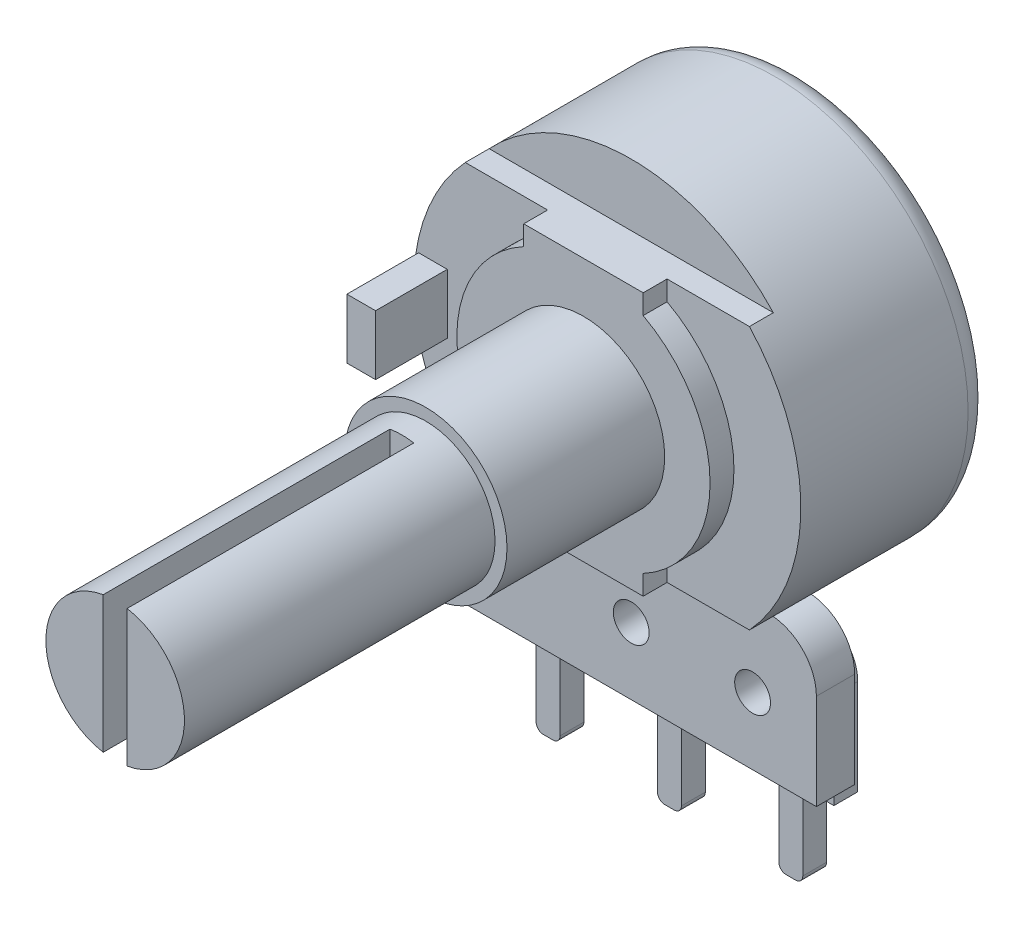
from build123d import *
from build123d.topology import SkipClean

# Parameters (mm, degrees)
IZIM1_R                     = 8.1
Y_KSEKLIK_EKSTR_ZYON1_DEPTH = 7
RADYUS1_R                   = 1
Y_KSEKLIK_EKSTR_ZYON2_DEPTH = 1
Y_KSEKLIK_EKSTR_ZYON3_DEPTH = 1
IZIM4_W                     = 1.2
IZIM4_H                     = 2.5
Y_KSEKLIK_EKSTR_ZYON4_DEPTH = 3
IZIM5_R                     = 3.4
Y_KSEKLIK_EKSTR_ZYON5_DEPTH = 6.6
IZIM6_R                     = 2.9
Y_KSEKLIK_EKSTR_ZYON6_DEPTH = 1
Y_KSEKLIK_EKSTR_ZYON7_DEPTH = 12
IZIM8_W                     = 13.702328024
IZIM8_H                     = 4.535329086
KES_EKSTR_ZYON1_DEPTH       = 3.5
Y_KSEKLIK_EKSTR_ZYON8_START = 1.9
IZIM9_R                     = 0.75
Y_KSEKLIK_EKSTR_ZYON8_DEPTH = 1.6
Y_KSEKLIK_EKSTR_ZYON9_DEPTH = 1


with BuildPart() as part:
    # Çizim1 → Yükseklik-Ekstrüzyon1 (new body)
    with BuildSketch(Plane.XY):
        Circle(IZIM1_R)
    extrude(amount=Y_KSEKLIK_EKSTR_ZYON1_DEPTH)

    # Radyus1
    radyus1_edges = [part.edges().sort_by_distance(p)[0] for p in [
        (-8.1, 0, 0),
    ]]
    fillet(radyus1_edges, radius=RADYUS1_R)

    # Çizim2 → Yükseklik-Ekstrüzyon2 (add)
    with SkipClean():  # the faces are left unmerged after this step: merging them gives an invalid solid
        with BuildSketch(Plane.XY.offset(7)):
            with BuildLine():
                Line((-5.946427499, 5.5), (5.946427499, 5.5))
                ThreePointArc((5.946427499, 5.5), (8.1, 0), (5.946427499, -5.5))
                Line((5.946427499, -5.5), (-5.946427499, -5.5))
                ThreePointArc((-5.946427499, -5.5), (-8.1, 0), (-5.946427499, 5.5))
            make_face()
        extrude(amount=Y_KSEKLIK_EKSTR_ZYON2_DEPTH)

    # Çizim3 → Yükseklik-Ekstrüzyon3 (add)
    with BuildSketch(Plane.XY.offset(8)):
        with BuildLine():
            Line((-2.5, 5.5), (2.5, 5.5))
            Line((2.5, 5.5), (2.5, 4.673328578))
            ThreePointArc((2.5, 4.673328578), (5.3, 0), (2.5, -4.673328578))
            Line((2.5, -4.673328578), (2.5, -5.5))
            Line((2.5, -5.5), (-2.5, -5.5))
            Line((-2.5, -5.5), (-2.5, -4.673328578))
            ThreePointArc((-2.5, -4.673328578), (-5.3, 0), (-2.5, 4.673328578))
            Line((-2.5, 4.673328578), (-2.5, 5.5))
        make_face()
    extrude(amount=Y_KSEKLIK_EKSTR_ZYON3_DEPTH)

    # Çizim4 → Yükseklik-Ekstrüzyon4 (add)
    with BuildSketch(Plane.XY.offset(8)):
        with Locations((-7.3, 0)):
            Rectangle(IZIM4_W, IZIM4_H)
    extrude(amount=Y_KSEKLIK_EKSTR_ZYON4_DEPTH)

    # Çizim5 → Yükseklik-Ekstrüzyon5 (add)
    with BuildSketch(Plane.XY.offset(9)):
        Circle(IZIM5_R)
    extrude(amount=Y_KSEKLIK_EKSTR_ZYON5_DEPTH)

    # Çizim6 → Yükseklik-Ekstrüzyon6 (add)
    with BuildSketch(Plane.XY.offset(15.6)):
        Circle(IZIM6_R)
    extrude(amount=Y_KSEKLIK_EKSTR_ZYON6_DEPTH)

    # Çizim7 → Yükseklik-Ekstrüzyon7 (add)
    with SkipClean():  # the faces are left unmerged after this step: merging them gives an invalid solid
        with BuildSketch(Plane.XY.offset(16.6)):
            with BuildLine():
                Line((-0.5, 2.856571371), (-0.5, -2.856571371))
                ThreePointArc((-0.5, -2.856571371), (-2.9, 0), (-0.5, 2.856571371))
            make_face()
            with BuildLine():
                Line((0.5, 2.856571371), (0.5, -2.856571371))
                ThreePointArc((0.5, -2.856571371), (2.9, 0), (0.5, 2.856571371))
            make_face()
        extrude(amount=Y_KSEKLIK_EKSTR_ZYON7_DEPTH)

    # Çizim8 → Kes-Ekstrüzyon1 (cut)
    with BuildSketch(Plane.XY.offset(7)):
        with Locations((0.904736513, -7.767664543)):
            Rectangle(IZIM8_W, IZIM8_H)
    extrude(amount=-KES_EKSTR_ZYON1_DEPTH, mode=Mode.SUBTRACT)

    # Çizim9 → Yükseklik-Ekstrüzyon8 (add)
    with BuildSketch(Plane.XY.offset(3.5).offset(Y_KSEKLIK_EKSTR_ZYON8_START)):
        with BuildLine():
            Line((-7.75, -11.5), (7.75, -11.5))
            Line((7.75, -11.5), (7.75, -7.5))
            ThreePointArc((7.75, -7.5), (7.164213562, -6.085786438), (5.75, -5.5))
            Line((5.75, -5.5), (-5.75, -5.5))
            ThreePointArc((-5.75, -5.5), (-7.164213562, -6.085786438), (-7.75, -7.5))
            Line((-7.75, -7.5), (-7.75, -11.5))
        make_face()
        with Locations((0, -8.7)):
            Circle(IZIM9_R, mode=Mode.SUBTRACT)
        with Locations((5.08, -8.7)):
            Circle(IZIM9_R, mode=Mode.SUBTRACT)
        with Locations((-5.08, -8.7)):
            Circle(IZIM9_R, mode=Mode.SUBTRACT)
    extrude(amount=Y_KSEKLIK_EKSTR_ZYON8_DEPTH)

    # Çizim10 → Yükseklik-Ekstrüzyon9 (add)
    with BuildSketch(Plane(origin=(0, 0, 5.4), x_dir=(-1, 0, 0), z_dir=(0, 0, -1))):
        with BuildLine():
            Line((3.53, -12.7), (4.58, -12))
            Line((4.58, -12), (4.58, -15.9))
            ThreePointArc((4.58, -15.9), (4.667867966, -16.112132034), (4.88, -16.2))
            Line((4.88, -16.2), (5.28, -16.2))
            ThreePointArc((5.28, -16.2), (5.492132034, -16.112132034), (5.58, -15.9))
            Line((5.58, -15.9), (5.58, -12))
            Line((5.58, -12), (6.63, -12.7))
            Line((6.63, -12.7), (6.88, -12.7))
            Line((6.88, -12.7), (6.88, -8.7))
            ThreePointArc((6.88, -8.7), (5.08, -6.9), (3.28, -8.7))
            Line((3.28, -8.7), (3.28, -12.7))
            Line((3.28, -12.7), (3.53, -12.7))
        make_face()
        with BuildLine():
            Line((-1.55, -12.7), (-0.5, -12))
            Line((-0.5, -12), (-0.5, -15.9))
            ThreePointArc((-0.5, -15.9), (-0.412132034, -16.112132034), (-0.2, -16.2))
            Line((-0.2, -16.2), (0.2, -16.2))
            ThreePointArc((0.2, -16.2), (0.412132034, -16.112132034), (0.5, -15.9))
            Line((0.5, -15.9), (0.5, -12))
            Line((0.5, -12), (1.55, -12.7))
            Line((1.55, -12.7), (1.8, -12.7))
            Line((1.8, -12.7), (1.8, -8.7))
            ThreePointArc((1.8, -8.7), (0, -6.9), (-1.8, -8.7))
            Line((-1.8, -8.7), (-1.8, -12.7))
            Line((-1.8, -12.7), (-1.55, -12.7))
        make_face()
        with BuildLine():
            Line((-6.63, -12.7), (-5.58, -12))
            Line((-5.58, -12), (-5.58, -15.9))
            ThreePointArc((-5.58, -15.9), (-5.492132034, -16.112132034), (-5.28, -16.2))
            Line((-5.28, -16.2), (-4.88, -16.2))
            ThreePointArc((-4.88, -16.2), (-4.667867966, -16.112132034), (-4.58, -15.9))
            Line((-4.58, -15.9), (-4.58, -12))
            Line((-4.58, -12), (-3.53, -12.7))
            Line((-3.53, -12.7), (-3.28, -12.7))
            Line((-3.28, -12.7), (-3.28, -8.7))
            ThreePointArc((-3.28, -8.7), (-5.08, -6.9), (-6.88, -8.7))
            Line((-6.88, -8.7), (-6.88, -12.7))
            Line((-6.88, -12.7), (-6.63, -12.7))
        make_face()
    extrude(amount=Y_KSEKLIK_EKSTR_ZYON9_DEPTH)


solid = part.part
